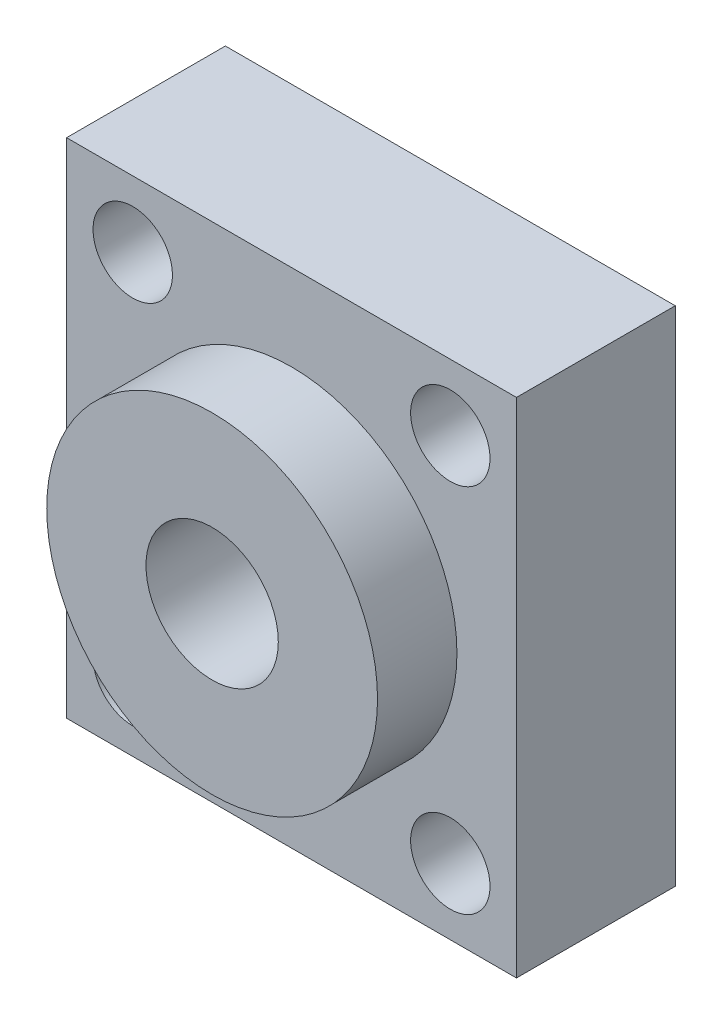
from build123d import *

# Parameters (mm, degrees)
SKETCH1_W            = 34
SKETCH1_H            = 38
BOSS_EXTRUDE1_DEPTH  = 12
SKETCH_1_R           = 12.5
EXTRUDE_1_DEPTH      = 6
SKETCH_2_R           = 5
CUT_EXTRUDE_1_DEPTH  = 100
SKETCH2_R            = 3
CUT_EXTRUDE1_DEPTH   = 5
LPATTERN1_COUNT      = 2
LPATTERN1_PITCH      = 24
LPATTERN1_COUNT_DIR2 = 2
LPATTERN1_PITCH_DIR2 = 28


with BuildPart() as part:
    # Sketch1 → Boss-Extrude1 (new body)
    with BuildSketch(Plane.XY):
        with Locations((-1.444444444, -6.888888889)):
            Rectangle(SKETCH1_W, SKETCH1_H)
    extrude(amount=BOSS_EXTRUDE1_DEPTH)

    # Эскиз1 → Бобышка-Вытянуть1 (add)
    with BuildSketch(Plane.XY.offset(12)):
        with Locations((-1.444444444, -6.888888889)):
            Circle(SKETCH_1_R)
    extrude(amount=EXTRUDE_1_DEPTH)

    # Эскиз2 → Вырез-Вытянуть1 (cut)
    with BuildSketch(Plane.XY.offset(18)):
        with Locations((-1.444444444, -6.888888889)):
            Circle(SKETCH_2_R)
    extrude(amount=-CUT_EXTRUDE_1_DEPTH, mode=Mode.SUBTRACT)

    # Sketch2 → Cut-Extrude1 (cut)
    with BuildSketch(Plane.XY.offset(12)):
        with Locations((-13.444444444, 7.111111111)):
            Circle(SKETCH2_R)
    cut_extrude1 = extrude(amount=-CUT_EXTRUDE1_DEPTH, mode=Mode.SUBTRACT)

    # LPattern1: Cut-Extrude1 2 × 2
    with Locations(*[(i * LPATTERN1_PITCH, -j * LPATTERN1_PITCH_DIR2, 0) for i in range(LPATTERN1_COUNT) for j in range(LPATTERN1_COUNT_DIR2) if (i, j) != (0, 0)]):
        add(cut_extrude1, mode=Mode.SUBTRACT)


solid = part.part
